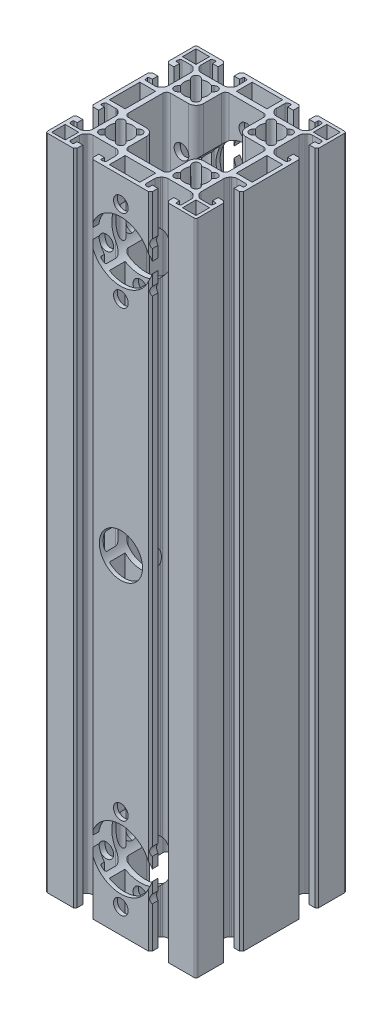
from build123d import *

# Parameters (mm, degrees)
SKETCH1_W           = 8.4
SKETCH1_H           = 16.2
SKETCH1_W_2         = 7.2
SKETCH1_H_2         = 7.2
SKETCH1_W_3         = 16.2
SKETCH1_H_3         = 8.4
BOSS_EXTRUDE1_DEPTH = 350
SKETCH2_R           = 11.5
SKETCH2_R_2         = 16
SKETCH2_R_3         = 3.9
SKETCH2_R_4         = 4
CUT_EXTRUDE1_DEPTH  = 81


with BuildPart() as part:
    # Sketch1 → Boss-Extrude1 (new body)
    with BuildSketch(Plane(origin=(0, 0, 0), x_dir=(1, 0, 0), z_dir=(0, 1, 0))):
        with BuildLine():
            Line((39.881157874, -42.704615906), (39.881157874, -28.954615906))
            Line((39.881157874, -28.954615906), (38.881157874, -27.954615906))
            Line((38.881157874, -27.954615906), (35.881157874, -27.954615906))
            Line((35.881157874, -27.954615906), (35.881157874, -30.954615906))
            Line((35.881157874, -30.954615906), (37.485281077, -30.954615906))
            ThreePointArc((37.485281077, -30.954615906), (37.868303299, -31.133222101), (37.977684954, -31.541439995))
            Line((37.977684954, -31.541439995), (37.797926779, -32.560899266))
            ThreePointArc((37.797926779, -32.560899266), (37.49010865, -33.094055905), (36.911599801, -33.304615906))
            Line((36.911599801, -33.304615906), (32.215023493, -33.304615906))
            ThreePointArc((32.215023493, -33.304615906), (31.066973196, -33.076254504), (30.09370315, -32.42593625))
            Line((30.09370315, -32.42593625), (29.55983753, -31.89207063))
            ThreePointArc((29.55983753, -31.89207063), (28.909519276, -30.918800583), (28.681157874, -29.770750286))
            Line((28.681157874, -29.770750286), (28.681157874, -17.638481526))
            ThreePointArc((28.681157874, -17.638481526), (28.909519276, -16.490431229), (29.55983753, -15.517161182))
            Line((29.55983753, -15.517161182), (30.09370315, -14.983295562))
            ThreePointArc((30.09370315, -14.983295562), (31.066973196, -14.332977309), (32.215023493, -14.104615906))
            Line((32.215023493, -14.104615906), (36.911599801, -14.104615906))
            ThreePointArc((36.911599801, -14.104615906), (37.49010865, -14.315175907), (37.797926779, -14.848332546))
            Line((37.797926779, -14.848332546), (37.977684954, -15.867791817))
            ThreePointArc((37.977684954, -15.867791817), (37.868303299, -16.276009711), (37.485281077, -16.454615906))
            Line((37.485281077, -16.454615906), (35.881157874, -16.454615906))
            Line((35.881157874, -16.454615906), (35.881157874, -19.454615906))
            Line((35.881157874, -19.454615906), (38.881157874, -19.454615906))
            Line((38.881157874, -19.454615906), (39.881157874, -18.454615906))
            Line((39.881157874, -18.454615906), (39.881157874, 11.045384094))
            Line((39.881157874, 11.045384094), (38.881157874, 12.045384094))
            Line((38.881157874, 12.045384094), (35.881157874, 12.045384094))
            Line((35.881157874, 12.045384094), (35.881157874, 9.045384094))
            Line((35.881157874, 9.045384094), (37.485281077, 9.045384094))
            ThreePointArc((37.485281077, 9.045384094), (37.868303299, 8.866777899), (37.977684954, 8.458560005))
            Line((37.977684954, 8.458560005), (37.797926779, 7.439100734))
            ThreePointArc((37.797926779, 7.439100734), (37.49010865, 6.905944095), (36.911599801, 6.695384094))
            Line((36.911599801, 6.695384094), (32.215023493, 6.695384094))
            ThreePointArc((32.215023493, 6.695384094), (31.066973196, 6.923745496), (30.09370315, 7.57406375))
            Line((30.09370315, 7.57406375), (29.55983753, 8.10792937))
            ThreePointArc((29.55983753, 8.10792937), (28.909519276, 9.081199417), (28.681157874, 10.229249714))
            Line((28.681157874, 10.229249714), (28.681157874, 22.361518474))
            ThreePointArc((28.681157874, 22.361518474), (28.909519276, 23.509568771), (29.55983753, 24.482838818))
            Line((29.55983753, 24.482838818), (30.09370315, 25.016704438))
            ThreePointArc((30.09370315, 25.016704438), (31.066973196, 25.667022691), (32.215023493, 25.895384094))
            Line((32.215023493, 25.895384094), (36.911599801, 25.895384094))
            ThreePointArc((36.911599801, 25.895384094), (37.49010865, 25.684824093), (37.797926779, 25.151667454))
            Line((37.797926779, 25.151667454), (37.977684954, 24.132208183))
            ThreePointArc((37.977684954, 24.132208183), (37.868303299, 23.723990289), (37.485281077, 23.545384094))
            Line((37.485281077, 23.545384094), (35.881157874, 23.545384094))
            Line((35.881157874, 23.545384094), (35.881157874, 20.545384094))
            Line((35.881157874, 20.545384094), (38.881157874, 20.545384094))
            Line((38.881157874, 20.545384094), (39.881157874, 21.545384094))
            Line((39.881157874, 21.545384094), (39.881157874, 35.295384094))
            ThreePointArc((39.881157874, 35.295384094), (39.588264655, 36.002490875), (38.881157874, 36.295384094))
            Line((38.881157874, 36.295384094), (25.131157874, 36.295384094))
            Line((25.131157874, 36.295384094), (24.131157874, 35.295384094))
            Line((24.131157874, 35.295384094), (24.131157874, 32.295384094))
            Line((24.131157874, 32.295384094), (27.131157874, 32.295384094))
            Line((27.131157874, 32.295384094), (27.131157874, 33.899507298))
            ThreePointArc((27.131157874, 33.899507298), (27.309764069, 34.282529519), (27.717981962, 34.391911174))
            Line((27.717981962, 34.391911174), (28.737441233, 34.212152999))
            ThreePointArc((28.737441233, 34.212152999), (29.270597872, 33.90433487), (29.481157874, 33.325826021))
            Line((29.481157874, 33.325826021), (29.481157874, 28.629249714))
            ThreePointArc((29.481157874, 28.629249714), (29.252796471, 27.481199417), (28.602478217, 26.50792937))
            Line((28.602478217, 26.50792937), (28.068612597, 25.97406375))
            ThreePointArc((28.068612597, 25.97406375), (27.095342551, 25.323745496), (25.947292254, 25.095384094))
            Line((25.947292254, 25.095384094), (13.815023493, 25.095384094))
            ThreePointArc((13.815023493, 25.095384094), (12.666973196, 25.323745496), (11.69370315, 25.97406375))
            Line((11.69370315, 25.97406375), (11.15983753, 26.50792937))
            ThreePointArc((11.15983753, 26.50792937), (10.509519276, 27.481199417), (10.281157874, 28.629249714))
            Line((10.281157874, 28.629249714), (10.281157874, 33.325826021))
            ThreePointArc((10.281157874, 33.325826021), (10.491717875, 33.90433487), (11.024874514, 34.212152999))
            Line((11.024874514, 34.212152999), (12.044333785, 34.391911174))
            ThreePointArc((12.044333785, 34.391911174), (12.452551678, 34.282529519), (12.631157874, 33.899507298))
            Line((12.631157874, 33.899507298), (12.631157874, 32.295384094))
            Line((12.631157874, 32.295384094), (15.631157874, 32.295384094))
            Line((15.631157874, 32.295384094), (15.631157874, 35.295384094))
            Line((15.631157874, 35.295384094), (14.631157874, 36.295384094))
            Line((14.631157874, 36.295384094), (-14.868842126, 36.295384094))
            Line((-14.868842126, 36.295384094), (-15.868842126, 35.295384094))
            Line((-15.868842126, 35.295384094), (-15.868842126, 32.295384094))
            Line((-15.868842126, 32.295384094), (-12.868842126, 32.295384094))
            Line((-12.868842126, 32.295384094), (-12.868842126, 33.899507298))
            ThreePointArc((-12.868842126, 33.899507298), (-12.690235931, 34.282529519), (-12.282018038, 34.391911174))
            Line((-12.282018038, 34.391911174), (-11.262558767, 34.212152999))
            ThreePointArc((-11.262558767, 34.212152999), (-10.729402128, 33.90433487), (-10.518842126, 33.325826021))
            Line((-10.518842126, 33.325826021), (-10.518842126, 28.629249714))
            ThreePointArc((-10.518842126, 28.629249714), (-10.747203529, 27.481199417), (-11.397521783, 26.50792937))
            Line((-11.397521783, 26.50792937), (-11.931387403, 25.97406375))
            ThreePointArc((-11.931387403, 25.97406375), (-12.904657449, 25.323745496), (-14.052707746, 25.095384094))
            Line((-14.052707746, 25.095384094), (-26.184976507, 25.095384094))
            ThreePointArc((-26.184976507, 25.095384094), (-27.333026804, 25.323745496), (-28.30629685, 25.97406375))
            Line((-28.30629685, 25.97406375), (-28.84016247, 26.50792937))
            ThreePointArc((-28.84016247, 26.50792937), (-29.490480724, 27.481199417), (-29.718842126, 28.629249714))
            Line((-29.718842126, 28.629249714), (-29.718842126, 33.325826021))
            ThreePointArc((-29.718842126, 33.325826021), (-29.508282125, 33.90433487), (-28.975125486, 34.212152999))
            Line((-28.975125486, 34.212152999), (-27.955666215, 34.391911174))
            ThreePointArc((-27.955666215, 34.391911174), (-27.547448322, 34.282529519), (-27.368842126, 33.899507298))
            Line((-27.368842126, 33.899507298), (-27.368842126, 32.295384094))
            Line((-27.368842126, 32.295384094), (-24.368842126, 32.295384094))
            Line((-24.368842126, 32.295384094), (-24.368842126, 35.295384094))
            Line((-24.368842126, 35.295384094), (-25.368842126, 36.295384094))
            Line((-25.368842126, 36.295384094), (-39.118842126, 36.295384094))
            ThreePointArc((-39.118842126, 36.295384094), (-39.825948908, 36.002490875), (-40.118842126, 35.295384094))
            Line((-40.118842126, 35.295384094), (-40.118842126, 21.545384094))
            Line((-40.118842126, 21.545384094), (-39.118842126, 20.545384094))
            Line((-39.118842126, 20.545384094), (-36.118842126, 20.545384094))
            Line((-36.118842126, 20.545384094), (-36.118842126, 23.545384094))
            Line((-36.118842126, 23.545384094), (-37.72296533, 23.545384094))
            ThreePointArc((-37.72296533, 23.545384094), (-38.105987552, 23.723990289), (-38.215369207, 24.132208183))
            Line((-38.215369207, 24.132208183), (-38.035611031, 25.151667454))
            ThreePointArc((-38.035611031, 25.151667454), (-37.727792902, 25.684824093), (-37.149284054, 25.895384094))
            Line((-37.149284054, 25.895384094), (-32.452707746, 25.895384094))
            ThreePointArc((-32.452707746, 25.895384094), (-31.304657449, 25.667022691), (-30.331387403, 25.016704438))
            Line((-30.331387403, 25.016704438), (-29.797521783, 24.482838818))
            ThreePointArc((-29.797521783, 24.482838818), (-29.147203529, 23.509568771), (-28.918842126, 22.361518474))
            Line((-28.918842126, 22.361518474), (-28.918842126, 10.229249714))
            ThreePointArc((-28.918842126, 10.229249714), (-29.147203529, 9.081199417), (-29.797521783, 8.10792937))
            Line((-29.797521783, 8.10792937), (-30.331387403, 7.57406375))
            ThreePointArc((-30.331387403, 7.57406375), (-31.304657449, 6.923745496), (-32.452707746, 6.695384094))
            Line((-32.452707746, 6.695384094), (-37.149284054, 6.695384094))
            ThreePointArc((-37.149284054, 6.695384094), (-37.727792902, 6.905944095), (-38.035611031, 7.439100734))
            Line((-38.035611031, 7.439100734), (-38.215369207, 8.458560005))
            ThreePointArc((-38.215369207, 8.458560005), (-38.105987552, 8.866777899), (-37.72296533, 9.045384094))
            Line((-37.72296533, 9.045384094), (-36.118842126, 9.045384094))
            Line((-36.118842126, 9.045384094), (-36.118842126, 12.045384094))
            Line((-36.118842126, 12.045384094), (-39.118842126, 12.045384094))
            Line((-39.118842126, 12.045384094), (-40.118842126, 11.045384094))
            Line((-40.118842126, 11.045384094), (-40.118842126, -18.454615906))
            Line((-40.118842126, -18.454615906), (-39.118842126, -19.454615906))
            Line((-39.118842126, -19.454615906), (-36.118842126, -19.454615906))
            Line((-36.118842126, -19.454615906), (-36.118842126, -16.454615906))
            Line((-36.118842126, -16.454615906), (-37.72296533, -16.454615906))
            ThreePointArc((-37.72296533, -16.454615906), (-38.105987552, -16.276009711), (-38.215369207, -15.867791817))
            Line((-38.215369207, -15.867791817), (-38.035611031, -14.848332546))
            ThreePointArc((-38.035611031, -14.848332546), (-37.727792902, -14.315175907), (-37.149284054, -14.104615906))
            Line((-37.149284054, -14.104615906), (-32.452707746, -14.104615906))
            ThreePointArc((-32.452707746, -14.104615906), (-31.304657449, -14.332977309), (-30.331387403, -14.983295562))
            Line((-30.331387403, -14.983295562), (-29.797521783, -15.517161182))
            ThreePointArc((-29.797521783, -15.517161182), (-29.147203529, -16.490431229), (-28.918842126, -17.638481526))
            Line((-28.918842126, -17.638481526), (-28.918842126, -29.770750286))
            ThreePointArc((-28.918842126, -29.770750286), (-29.147203529, -30.918800583), (-29.797521783, -31.89207063))
            Line((-29.797521783, -31.89207063), (-30.331387403, -32.42593625))
            ThreePointArc((-30.331387403, -32.42593625), (-31.304657449, -33.076254504), (-32.452707746, -33.304615906))
            Line((-32.452707746, -33.304615906), (-37.149284054, -33.304615906))
            ThreePointArc((-37.149284054, -33.304615906), (-37.727792902, -33.094055905), (-38.035611031, -32.560899266))
            Line((-38.035611031, -32.560899266), (-38.215369207, -31.541439995))
            ThreePointArc((-38.215369207, -31.541439995), (-38.105987552, -31.133222101), (-37.72296533, -30.954615906))
            Line((-37.72296533, -30.954615906), (-36.118842126, -30.954615906))
            Line((-36.118842126, -30.954615906), (-36.118842126, -27.954615906))
            Line((-36.118842126, -27.954615906), (-39.118842126, -27.954615906))
            Line((-39.118842126, -27.954615906), (-40.118842126, -28.954615906))
            Line((-40.118842126, -28.954615906), (-40.118842126, -42.704615906))
            ThreePointArc((-40.118842126, -42.704615906), (-39.825948908, -43.411722687), (-39.118842126, -43.704615906))
            Line((-39.118842126, -43.704615906), (-25.368842126, -43.704615906))
            Line((-25.368842126, -43.704615906), (-24.368842126, -42.704615906))
            Line((-24.368842126, -42.704615906), (-24.368842126, -39.704615906))
            Line((-24.368842126, -39.704615906), (-27.368842126, -39.704615906))
            Line((-27.368842126, -39.704615906), (-27.368842126, -41.30873911))
            ThreePointArc((-27.368842126, -41.30873911), (-27.547448322, -41.691761331), (-27.955666215, -41.801142986))
            Line((-27.955666215, -41.801142986), (-28.975125486, -41.621384811))
            ThreePointArc((-28.975125486, -41.621384811), (-29.508282125, -41.313566682), (-29.718842126, -40.735057833))
            Line((-29.718842126, -40.735057833), (-29.718842126, -36.038481526))
            ThreePointArc((-29.718842126, -36.038481526), (-29.490480724, -34.890431229), (-28.84016247, -33.917161182))
            Line((-28.84016247, -33.917161182), (-28.30629685, -33.383295562))
            ThreePointArc((-28.30629685, -33.383295562), (-27.333026804, -32.732977309), (-26.184976507, -32.504615906))
            Line((-26.184976507, -32.504615906), (-14.052707746, -32.504615906))
            ThreePointArc((-14.052707746, -32.504615906), (-12.904657449, -32.732977309), (-11.931387403, -33.383295562))
            Line((-11.931387403, -33.383295562), (-11.397521783, -33.917161182))
            ThreePointArc((-11.397521783, -33.917161182), (-10.747203529, -34.890431229), (-10.518842126, -36.038481526))
            Line((-10.518842126, -36.038481526), (-10.518842126, -40.735057833))
            ThreePointArc((-10.518842126, -40.735057833), (-10.729402128, -41.313566682), (-11.262558767, -41.621384811))
            Line((-11.262558767, -41.621384811), (-12.282018038, -41.801142986))
            ThreePointArc((-12.282018038, -41.801142986), (-12.690235931, -41.691761331), (-12.868842126, -41.30873911))
            Line((-12.868842126, -41.30873911), (-12.868842126, -39.704615906))
            Line((-12.868842126, -39.704615906), (-15.868842126, -39.704615906))
            Line((-15.868842126, -39.704615906), (-15.868842126, -42.704615906))
            Line((-15.868842126, -42.704615906), (-14.868842126, -43.704615906))
            Line((-14.868842126, -43.704615906), (14.631157874, -43.704615906))
            Line((14.631157874, -43.704615906), (15.631157874, -42.704615906))
            Line((15.631157874, -42.704615906), (15.631157874, -39.704615906))
            Line((15.631157874, -39.704615906), (12.631157874, -39.704615906))
            Line((12.631157874, -39.704615906), (12.631157874, -41.30873911))
            ThreePointArc((12.631157874, -41.30873911), (12.452551678, -41.691761331), (12.044333785, -41.801142986))
            Line((12.044333785, -41.801142986), (11.024874514, -41.621384811))
            ThreePointArc((11.024874514, -41.621384811), (10.491717875, -41.313566682), (10.281157874, -40.735057833))
            Line((10.281157874, -40.735057833), (10.281157874, -36.038481526))
            ThreePointArc((10.281157874, -36.038481526), (10.509519276, -34.890431229), (11.15983753, -33.917161182))
            Line((11.15983753, -33.917161182), (11.69370315, -33.383295562))
            ThreePointArc((11.69370315, -33.383295562), (12.666973196, -32.732977309), (13.815023493, -32.504615906))
            Line((13.815023493, -32.504615906), (25.947292254, -32.504615906))
            ThreePointArc((25.947292254, -32.504615906), (27.095342551, -32.732977309), (28.068612597, -33.383295562))
            Line((28.068612597, -33.383295562), (28.602478217, -33.917161182))
            ThreePointArc((28.602478217, -33.917161182), (29.252796471, -34.890431229), (29.481157874, -36.038481526))
            Line((29.481157874, -36.038481526), (29.481157874, -40.735057833))
            ThreePointArc((29.481157874, -40.735057833), (29.270597872, -41.313566682), (28.737441233, -41.621384811))
            Line((28.737441233, -41.621384811), (27.717981962, -41.801142986))
            ThreePointArc((27.717981962, -41.801142986), (27.309764069, -41.691761331), (27.131157874, -41.30873911))
            Line((27.131157874, -41.30873911), (27.131157874, -39.704615906))
            Line((27.131157874, -39.704615906), (24.131157874, -39.704615906))
            Line((24.131157874, -39.704615906), (24.131157874, -42.704615906))
            Line((24.131157874, -42.704615906), (25.131157874, -43.704615906))
            Line((25.131157874, -43.704615906), (38.881157874, -43.704615906))
            ThreePointArc((38.881157874, -43.704615906), (39.588264655, -43.411722687), (39.881157874, -42.704615906))
        make_face()
        with BuildLine():
            Line((16.522400663, 10.108199759), (17.10833788, 10.694136975))
            ThreePointArc((17.10833788, 10.694136975), (19.881157874, 10.045384094), (22.653977867, 10.694136975))
            Line((22.653977867, 10.694136975), (23.239915084, 10.108199759))
            ThreePointArc((23.239915084, 10.108199759), (26.068342209, 10.108199759), (26.068342209, 12.936626883))
            Line((26.068342209, 12.936626883), (25.482404992, 13.5225641))
            ThreePointArc((25.482404992, 13.5225641), (26.131157874, 16.295384094), (25.482404992, 19.068204088))
            Line((25.482404992, 19.068204088), (26.068342209, 19.654141305))
            ThreePointArc((26.068342209, 19.654141305), (26.068342209, 22.482568429), (23.239915084, 22.482568429))
            Line((23.239915084, 22.482568429), (22.653977867, 21.896631212))
            ThreePointArc((22.653977867, 21.896631212), (19.881157874, 22.545384094), (17.10833788, 21.896631212))
            Line((17.10833788, 21.896631212), (16.522400663, 22.482568429))
            ThreePointArc((16.522400663, 22.482568429), (13.693973538, 22.482568429), (13.693973538, 19.654141305))
            Line((13.693973538, 19.654141305), (14.279910755, 19.068204088))
            ThreePointArc((14.279910755, 19.068204088), (13.631157874, 16.295384094), (14.279910755, 13.5225641))
            Line((14.279910755, 13.5225641), (13.693973538, 12.936626883))
            ThreePointArc((13.693973538, 12.936626883), (13.693973538, 10.108199759), (16.522400663, 10.108199759))
        make_face(mode=Mode.SUBTRACT)
        with Locations((-33.918842126, -3.704615906)):
            Rectangle(SKETCH1_W, SKETCH1_H, mode=Mode.SUBTRACT)
        with BuildLine():
            Line((-23.477599337, 10.108199759), (-22.89166212, 10.694136975))
            ThreePointArc((-22.89166212, 10.694136975), (-20.118842126, 10.045384094), (-17.346022133, 10.694136975))
            Line((-17.346022133, 10.694136975), (-16.760084916, 10.108199759))
            ThreePointArc((-16.760084916, 10.108199759), (-13.931657791, 10.108199759), (-13.931657791, 12.936626883))
            Line((-13.931657791, 12.936626883), (-14.517595008, 13.5225641))
            ThreePointArc((-14.517595008, 13.5225641), (-13.868842126, 16.295384094), (-14.517595008, 19.068204088))
            Line((-14.517595008, 19.068204088), (-13.931657791, 19.654141305))
            ThreePointArc((-13.931657791, 19.654141305), (-13.931657791, 22.482568429), (-16.760084916, 22.482568429))
            Line((-16.760084916, 22.482568429), (-17.346022133, 21.896631212))
            ThreePointArc((-17.346022133, 21.896631212), (-20.118842126, 22.545384094), (-22.89166212, 21.896631212))
            Line((-22.89166212, 21.896631212), (-23.477599337, 22.482568429))
            ThreePointArc((-23.477599337, 22.482568429), (-26.306026462, 22.482568429), (-26.306026462, 19.654141305))
            Line((-26.306026462, 19.654141305), (-25.720089245, 19.068204088))
            ThreePointArc((-25.720089245, 19.068204088), (-26.368842126, 16.295384094), (-25.720089245, 13.5225641))
            Line((-25.720089245, 13.5225641), (-26.306026462, 12.936626883))
            ThreePointArc((-26.306026462, 12.936626883), (-26.306026462, 10.108199759), (-23.477599337, 10.108199759))
        make_face(mode=Mode.SUBTRACT)
        with BuildLine():
            Line((23.239915084, -17.517431571), (22.653977867, -18.103368788))
            ThreePointArc((22.653977867, -18.103368788), (19.881157874, -17.454615906), (17.10833788, -18.103368788))
            Line((17.10833788, -18.103368788), (16.522400663, -17.517431571))
            ThreePointArc((16.522400663, -17.517431571), (13.693973538, -17.517431571), (13.693973538, -20.345858695))
            Line((13.693973538, -20.345858695), (14.279910755, -20.931795912))
            ThreePointArc((14.279910755, -20.931795912), (13.631157874, -23.704615906), (14.279910755, -26.4774359))
            Line((14.279910755, -26.4774359), (13.693973538, -27.063373117))
            ThreePointArc((13.693973538, -27.063373117), (13.693973538, -29.891800241), (16.522400663, -29.891800241))
            Line((16.522400663, -29.891800241), (17.10833788, -29.305863025))
            ThreePointArc((17.10833788, -29.305863025), (19.881157874, -29.954615906), (22.653977867, -29.305863025))
            Line((22.653977867, -29.305863025), (23.239915084, -29.891800241))
            ThreePointArc((23.239915084, -29.891800241), (26.068342209, -29.891800241), (26.068342209, -27.063373117))
            Line((26.068342209, -27.063373117), (25.482404992, -26.4774359))
            ThreePointArc((25.482404992, -26.4774359), (26.131157874, -23.704615906), (25.482404992, -20.931795912))
            Line((25.482404992, -20.931795912), (26.068342209, -20.345858695))
            ThreePointArc((26.068342209, -20.345858695), (26.068342209, -17.517431571), (23.239915084, -17.517431571))
        make_face(mode=Mode.SUBTRACT)
        with Locations((-34.918842126, -38.504615906)):
            Rectangle(SKETCH1_W_2, SKETCH1_H_2, mode=Mode.SUBTRACT)
        with BuildLine():
            Line((-16.760084916, -17.517431571), (-17.346022133, -18.103368788))
            ThreePointArc((-17.346022133, -18.103368788), (-20.118842126, -17.454615906), (-22.89166212, -18.103368788))
            Line((-22.89166212, -18.103368788), (-23.477599337, -17.517431571))
            ThreePointArc((-23.477599337, -17.517431571), (-26.306026462, -17.517431571), (-26.306026462, -20.345858695))
            Line((-26.306026462, -20.345858695), (-25.720089245, -20.931795912))
            ThreePointArc((-25.720089245, -20.931795912), (-26.368842126, -23.704615906), (-25.720089245, -26.4774359))
            Line((-25.720089245, -26.4774359), (-26.306026462, -27.063373117))
            ThreePointArc((-26.306026462, -27.063373117), (-26.306026462, -29.891800241), (-23.477599337, -29.891800241))
            Line((-23.477599337, -29.891800241), (-22.89166212, -29.305863025))
            ThreePointArc((-22.89166212, -29.305863025), (-20.118842126, -29.954615906), (-17.346022133, -29.305863025))
            Line((-17.346022133, -29.305863025), (-16.760084916, -29.891800241))
            ThreePointArc((-16.760084916, -29.891800241), (-13.931657791, -29.891800241), (-13.931657791, -27.063373117))
            Line((-13.931657791, -27.063373117), (-14.517595008, -26.4774359))
            ThreePointArc((-14.517595008, -26.4774359), (-13.868842126, -23.704615906), (-14.517595008, -20.931795912))
            Line((-14.517595008, -20.931795912), (-13.931657791, -20.345858695))
            ThreePointArc((-13.931657791, -20.345858695), (-13.931657791, -17.517431571), (-16.760084916, -17.517431571))
        make_face(mode=Mode.SUBTRACT)
        with Locations((-34.918842126, 31.095384094)):
            Rectangle(SKETCH1_W_2, SKETCH1_H_2, mode=Mode.SUBTRACT)
        with Locations((34.681157874, -38.504615906)):
            Rectangle(SKETCH1_W_2, SKETCH1_H_2, mode=Mode.SUBTRACT)
        with Locations((34.681157874, 31.095384094)):
            Rectangle(SKETCH1_W_2, SKETCH1_H_2, mode=Mode.SUBTRACT)
        with Locations((-0.118842126, 30.095384094)):
            Rectangle(SKETCH1_W_3, SKETCH1_H_3, mode=Mode.SUBTRACT)
        with BuildLine():
            Line((11.081157874, -28.504615906), (11.081157874, -18.904615906))
            ThreePointArc((11.081157874, -18.904615906), (12.252730749, -16.076188781), (15.081157874, -14.904615906))
            Line((15.081157874, -14.904615906), (24.681157874, -14.904615906))
            ThreePointArc((24.681157874, -14.904615906), (26.095371436, -14.318829468), (26.681157874, -12.904615906))
            Line((26.681157874, -12.904615906), (26.681157874, 5.495384094))
            ThreePointArc((26.681157874, 5.495384094), (26.095371436, 6.909597656), (24.681157874, 7.495384094))
            Line((24.681157874, 7.495384094), (15.081157874, 7.495384094))
            ThreePointArc((15.081157874, 7.495384094), (12.252730749, 8.666956969), (11.081157874, 11.495384094))
            Line((11.081157874, 11.495384094), (11.081157874, 21.095384094))
            ThreePointArc((11.081157874, 21.095384094), (10.495371436, 22.509597656), (9.081157874, 23.095384094))
            Line((9.081157874, 23.095384094), (-9.318842126, 23.095384094))
            ThreePointArc((-9.318842126, 23.095384094), (-10.733055689, 22.509597656), (-11.318842126, 21.095384094))
            Line((-11.318842126, 21.095384094), (-11.318842126, 11.495384094))
            ThreePointArc((-11.318842126, 11.495384094), (-12.490415002, 8.666956969), (-15.318842126, 7.495384094))
            Line((-15.318842126, 7.495384094), (-24.918842126, 7.495384094))
            ThreePointArc((-24.918842126, 7.495384094), (-26.333055689, 6.909597656), (-26.918842126, 5.495384094))
            Line((-26.918842126, 5.495384094), (-26.918842126, -12.904615906))
            ThreePointArc((-26.918842126, -12.904615906), (-26.333055689, -14.318829468), (-24.918842126, -14.904615906))
            Line((-24.918842126, -14.904615906), (-15.318842126, -14.904615906))
            ThreePointArc((-15.318842126, -14.904615906), (-12.490415002, -16.076188781), (-11.318842126, -18.904615906))
            Line((-11.318842126, -18.904615906), (-11.318842126, -28.504615906))
            ThreePointArc((-11.318842126, -28.504615906), (-10.733055689, -29.918829468), (-9.318842126, -30.504615906))
            Line((-9.318842126, -30.504615906), (9.081157874, -30.504615906))
            ThreePointArc((9.081157874, -30.504615906), (10.495371436, -29.918829468), (11.081157874, -28.504615906))
        make_face(mode=Mode.SUBTRACT)
        with Locations((-0.118842126, -37.504615906)):
            Rectangle(SKETCH1_W_3, SKETCH1_H_3, mode=Mode.SUBTRACT)
        with Locations((33.681157874, -3.704615906)):
            Rectangle(SKETCH1_W, SKETCH1_H, mode=Mode.SUBTRACT)
    extrude(amount=BOSS_EXTRUDE1_DEPTH)

    # Sketch2 → Cut-Extrude1 (cut, through all)
    with BuildSketch(Plane.XY.offset(43.704615906)):
        with Locations((-0.059421063, 175)):
            Circle(SKETCH2_R)
        with Locations((-0.106957914, 315)):
            Circle(SKETCH2_R_2)
        with Locations((-0.106957914, 293.130030835)):
            Circle(SKETCH2_R_3)
        with Locations((-19.046906791, 304.065015417)):
            Circle(SKETCH2_R_3)
        with Locations((-19.046906791, 325.934984583)):
            Circle(SKETCH2_R_3)
        with Locations((-0.106957914, 336.869969165)):
            Circle(SKETCH2_R_3)
        with Locations((18.832990963, 325.934984583)):
            Circle(SKETCH2_R_3)
        with Locations((18.832990963, 304.065015417)):
            Circle(SKETCH2_R_3)
        with Locations((18.832990963, 45.934984583)):
            Circle(SKETCH2_R_3)
        with Locations((18.832990963, 24.065015417)):
            Circle(SKETCH2_R_3)
        with Locations((-0.106957914, 13.130030835)):
            Circle(SKETCH2_R_3)
        with Locations((-19.046906791, 24.065015417)):
            Circle(SKETCH2_R_3)
        with Locations((-19.046906791, 45.934984583)):
            Circle(SKETCH2_R_3)
        with Locations((-0.106957914, 56.869969165)):
            Circle(SKETCH2_R_3)
        with Locations((-0.106957914, 35)):
            Circle(SKETCH2_R_2)
        with Locations((19.881157874, 203.518864445)):
            Circle(SKETCH2_R_4)
        with Locations((-20.0193625, 203.505316266)):
            Circle(SKETCH2_R_4)
        with Locations((19.881157874, 146.481135555)):
            Circle(SKETCH2_R_4)
        with Locations((-20.0193625, 146.494683734)):
            Circle(SKETCH2_R_4)
    extrude(amount=-CUT_EXTRUDE1_DEPTH, mode=Mode.SUBTRACT)


solid = part.part
